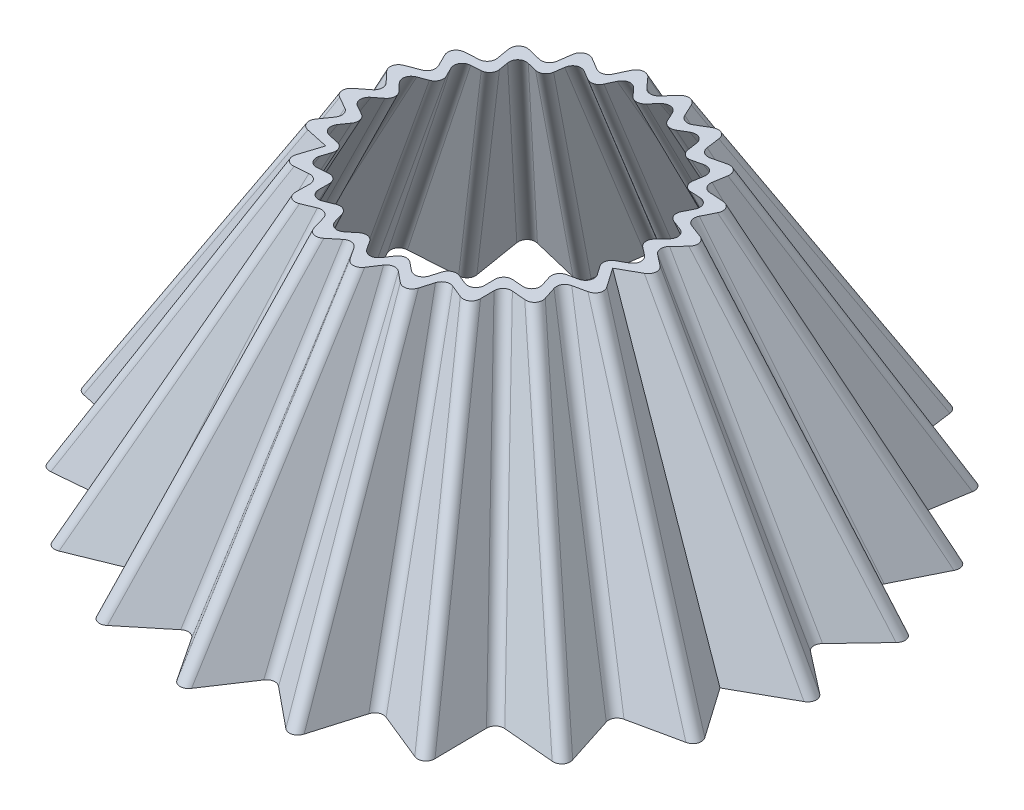
from build123d import *

# Parameters (mm, degrees)
BOSS_EXTRUDE1_DEPTH = 30
BOSS_EXTRUDE1_TAPER = 19
CUT_EXTRUDE1_DEPTH  = 30
CUT_EXTRUDE1_TAPER  = 19
FILLET1_R           = 1
FILLET2_R           = 1


with BuildPart() as part:
    # Sketch2 → Boss-Extrude1 (new body)
    with BuildSketch(Plane(origin=(0, 0, 0), x_dir=(1, 0, 0), z_dir=(0, 1, 0))):
        Polygon((-8.842655232, 28.667184174), (-15.793368104, 32.795266792), (-16.899601742, 24.787163229), (-24.758287655, 26.683088135), (-23.454944474, 18.704694056), (-31.523324698, 18.2), (-27.926212459, 10.960230731), (-35.487376003, 8.099761996), (-29.916113915, 2.241902808), (-36.298218217, -2.720175407), (-29.247837365, -6.675628019), (-33.883804451, -13.298413287), (-25.980762114, -15), (-28.458665962, -22.695028788), (-20.405182133, -21.991556155), (-20.504850114, -30.075091385), (-13.016512174, -27.029066037), (-10.729088349, -34.782850131), (-4.471267985, -29.664924787), (0, -36.4), (4.471267985, -29.664924787), (10.729088349, -34.782850131), (13.016512174, -27.029066037), (20.504850114, -30.075091385), (20.405182133, -21.991556155), (28.458665962, -22.695028788), (25.980762114, -15), (33.883804451, -13.298413287), (29.247837365, -6.675628019), (36.298218217, -2.720175407), (29.916113915, 2.241902808), (35.487376003, 8.099761996), (27.926212459, 10.960230731), (31.523324698, 18.2), (23.454944474, 18.704694056), (24.758287655, 26.683088135), (16.899601742, 24.787163229), (15.793368104, 32.795266792), (8.842655232, 28.667184174), (5.425138489, 35.993442075), (0, 30), (-5.425138489, 35.993442075), align=None)
    extrude(amount=BOSS_EXTRUDE1_DEPTH, taper=BOSS_EXTRUDE1_TAPER)

    # Sketch2_6 → Cut-Extrude1 (cut)
    with BuildSketch(Plane(origin=(0, 0, 0), x_dir=(1, 0, 0), z_dir=(0, 1, 0))):
        Polygon((-29.957531955, 17.295989138), (-26.539091614, 10.415825916), (-33.72468516, 7.697439314), (-28.430152821, 2.130545418), (-34.49525209, -2.585061774), (-27.795070187, -6.34404339), (-32.200764492, -12.637868779), (-24.690273589, -14.254936103), (-27.045097658, -21.567745682), (-19.391637832, -20.899215186), (-19.486355211, -28.581233733), (-12.369969955, -25.686507286), (-10.19616459, -33.05515374), (-4.249175962, -28.191440489), (0, -34.591978277), (4.249175962, -28.191440489), (10.19616459, -33.05515374), (12.369969955, -25.686507286), (19.486355211, -28.581233733), (19.391637832, -20.899215186), (27.045097658, -21.567745682), (24.690273589, -14.254936103), (32.200764492, -12.637868779), (27.795070187, -6.34404339), (34.49525209, -2.585061774), (28.430152821, 2.130545418), (33.72468516, 7.697439314), (26.539091614, 10.415825916), (29.957531955, 17.295989138), (22.289915652, 17.775614573), (23.528520569, 25.357714426), (16.060182867, 23.555961868), (15.008896878, 31.166295507), (8.403432355, 27.243258577), (5.155666834, 34.20561446), (0, 28.509872206), (-5.155666834, 34.20561446), (-8.403432355, 27.243258577), (-15.008896878, 31.166295507), (-16.060182867, 23.555961868), (-23.528520569, 25.357714426), (-22.289915652, 17.775614573), align=None)
    extrude(amount=CUT_EXTRUDE1_DEPTH, taper=CUT_EXTRUDE1_TAPER, mode=Mode.SUBTRACT)

    # Fillet1
    fillet1_edges = [part.edges().sort_by_distance(p)[0] for p in [
        (3.324181741, 15, 22.054504816),
        (9.677177086, 15, 20.094865278),
        (15.17031278, 15, 16.349708776),
        (19.31549961, 15, 11.151808899),
        (20.291652356, 15, 4.631437235),
        (22.24125236, 15, -1.666751445),
        (20.761852309, 15, -8.148426574),
        (17.437670568, 15, -13.906078242),
        (12.564075273, 15, -18.428113833),
        (6.574106754, 15, -21.312730639),
        (0, 15, -22.303617799),
        (-6.574106754, 15, -21.312730639),
        (-12.564075273, 15, -18.428113833),
        (-17.437670568, 15, -13.906078242),
        (-20.761852309, 15, -8.148426574),
        (-22.24125236, 15, -1.666751445),
        (-21.744419535, 15, 4.963021863),
        (-18.025011086, 15, 10.406745002),
        (-15.17031278, 15, 16.349708776),
        (-9.677177086, 15, 20.094865278),
        (-3.324181741, 15, 22.054504816),
        (-7.976582862, 15, 25.859446509),
        (0, 15, 27.061722929),
        (7.976582862, 15, 25.859446509),
        (15.244411332, 15, 22.359444784),
        (21.157706956, 15, 16.872708267),
        (25.191047468, 15, 9.886757576),
        (26.986052863, 15, 2.022325087),
        (26.383229035, 15, -6.021799861),
        (23.436139527, 15, -13.530861465),
        (18.406646174, 15, -19.837646648),
        (11.741641531, 15, -24.381769871),
        (4.033340512, 15, -26.759465843),
        (-4.033340512, 15, -26.759465843),
        (-11.741641531, 15, -24.381769871),
        (-17.176879088, 15, -18.51227294),
        (-23.436139527, 15, -13.530861465),
        (-26.383229035, 15, -6.021799861),
        (-26.986052863, 15, 2.022325087),
        (-25.191047468, 15, 9.886757576),
        (-21.157706956, 15, 16.872708267),
        (-15.244411332, 15, 22.359444784),
        (-18.406646174, 15, -19.837646648),
    ]]
    fillet(fillet1_edges, radius=FILLET1_R)

    # Fillet2
    fillet2_edges = [part.edges().sort_by_distance(p)[0] for p in [
        (0, 15, 25.253701206),
        (-3.102089717, 15, 20.581020518),
        (-7.443659104, 15, 24.131750118),
        (-9.030634867, 15, 18.752306527),
        (-14.22591643, 15, 20.865587131),
        (-14.156768479, 15, 15.257367807),
        (-19.744138652, 15, 15.745425161),
        (-23.508007509, 15, 9.226213068),
        (-20.291652356, 15, 4.631437235),
        (-25.183086736, 15, 1.887211455),
        (-20.755291266, 15, -1.555394056),
        (-24.620538192, 15, -5.619477178),
        (-19.374731463, 15, -7.604021759),
        (-21.870346784, 15, -12.626850603),
        (-16.272641746, 15, -12.976998759),
        (-11.724656398, 15, -17.196912471),
        (-10.957170306, 15, -22.752798586),
        (-6.134883877, 15, -19.888805042),
        (-3.763868857, 15, -24.971638229),
        (0, 15, -20.813490005),
        (3.763868857, 15, -24.971638229),
        (6.134883877, 15, -19.888805042),
        (23.508007509, 15, 9.226213068),
        (10.957170306, 15, -22.752798586),
        (11.724656398, 15, -17.196912471),
        (17.176879088, 15, -18.51227294),
        (16.272641746, 15, -12.976998759),
        (21.870346784, 15, -12.626850603),
        (19.374731463, 15, -7.604021759),
        (25.183086736, 15, 1.887211455),
        (24.620538192, 15, -5.619477178),
        (20.755291266, 15, -1.555394056),
        (18.025011086, 15, 10.406745002),
        (14.156768479, 15, 15.257367807),
        (19.744138652, 15, 15.745425161),
        (14.22591643, 15, 20.865587131),
        (9.030634867, 15, 18.752306527),
        (7.443659104, 15, 24.131750118),
        (3.102089717, 15, 20.581020518),
    ]]
    fillet(fillet2_edges, radius=FILLET2_R)


solid = part.part
